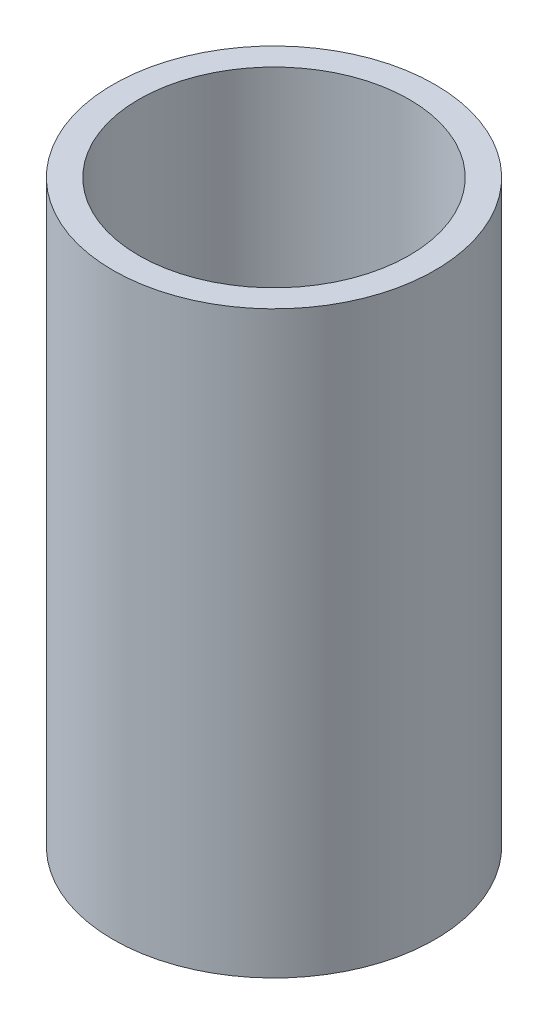
from build123d import *

# Parameters (mm, degrees)
SKETCH_1_R      = 5
SKETCH_1_R_2    = 4.2
EXTRUDE_1_DEPTH = 18


with BuildPart() as part:
    # 草图1 → 凸台-拉伸1 (new body)
    with BuildSketch(Plane(origin=(0, 0, 0), x_dir=(1, 0, 0), z_dir=(0, 1, 0))):
        Circle(SKETCH_1_R)
        Circle(SKETCH_1_R_2, mode=Mode.SUBTRACT)
    extrude(amount=EXTRUDE_1_DEPTH)


solid = part.part
